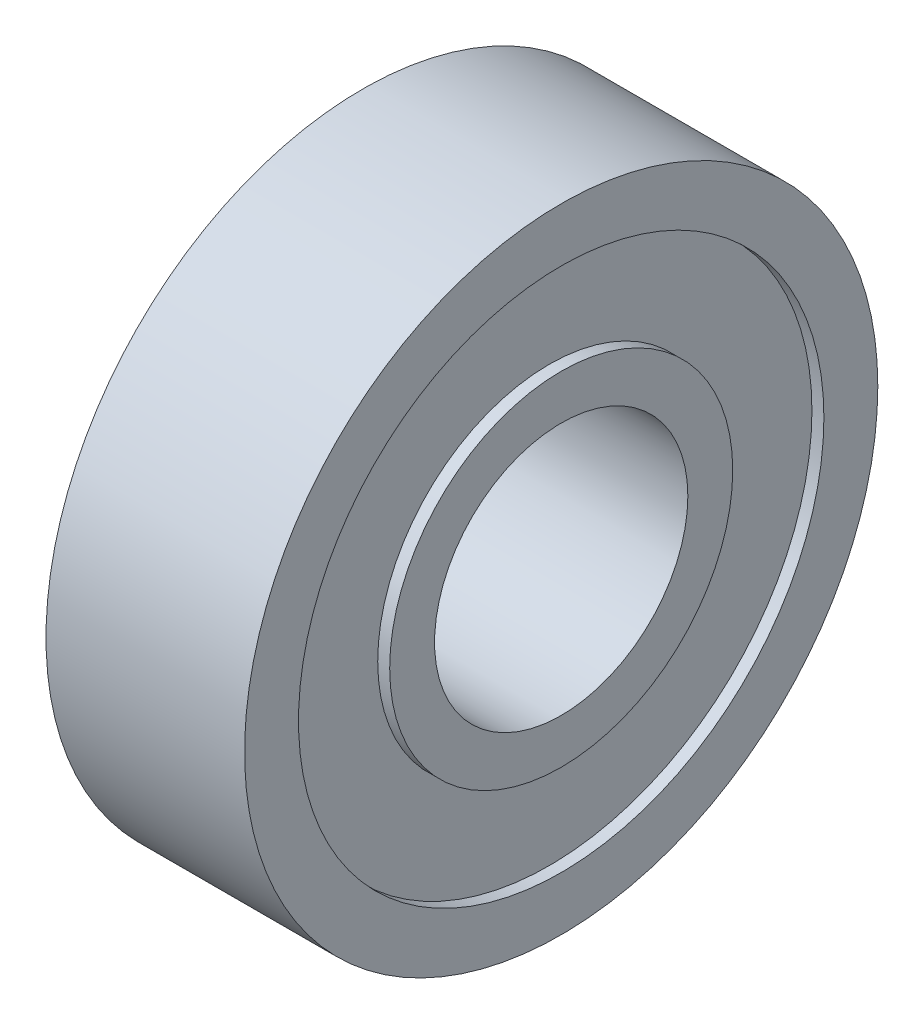
from build123d import *


with BuildPart() as part:
    # Sketch1 → Revolve1 (revolve)
    with BuildSketch(Plane.XY):
        Polygon((2.4892, 3.175), (-2.4892, 3.175), (-2.4892, 4.3), (-2.1892, 4.3), (-2.1892, 6.586), (-2.4892, 6.586), (-2.4892, 7.9375), (2.4892, 7.9375), (2.4892, 6.586), (2.1892, 6.586), (2.1892, 4.3), (2.4892, 4.3), align=None)
    revolve(axis=Axis((0, 0, 0), (-1, 0, 0)))


solid = part.part
